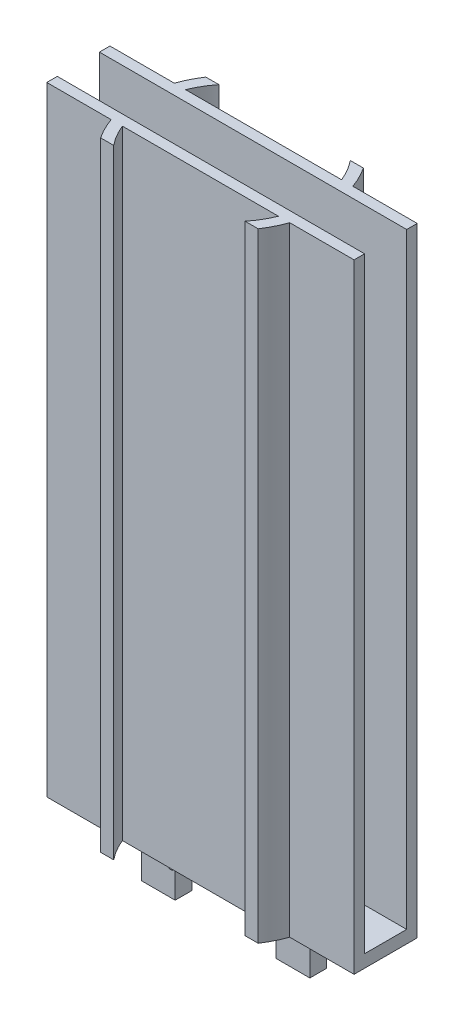
from build123d import *

# Parameters (mm, degrees)
BOSS_EXTRUDE1_DEPTH = 3
BOSS_EXTRUDE2_START = 144
BOSS_EXTRUDE2_DEPTH = 144
SKETCH2_W           = 8
SKETCH2_H           = 4
BOSS_EXTRUDE3_DEPTH = 12
SKETCH3_R           = 0.75
CUT_EXTRUDE1_DEPTH  = 163.14191315


with BuildPart() as part:
    # Sketch1 → Boss-Extrude1 (new body)
    with BuildSketch(Plane(origin=(0, 0, 0), x_dir=(1, 0, 0), z_dir=(0, 1, 0))):
        with BuildLine():
            Line((-17.959503782, 12.5), (-55.040496218, 12.5))
            ThreePointArc((-55.040496218, 12.5), (-53.758525494, 15.106596746), (-52.112494996, 17.5))
            Line((-52.112494996, 17.5), (-55.208286934, 17.5))
            ThreePointArc((-55.208286934, 17.5), (-56.616693275, 15.078127389), (-57.713203436, 12.5))
            Line((-57.713203436, 12.5), (-73, 12.5))
            Line((-73, 12.5), (-73, -2.5))
            Line((-73, -2.5), (-57.713203436, -2.5))
            ThreePointArc((-57.713203436, -2.5), (-56.616693275, -5.078127389), (-55.208286934, -7.5))
            Line((-55.208286934, -7.5), (-52.112494996, -7.5))
            ThreePointArc((-52.112494996, -7.5), (-53.758525494, -5.106596746), (-55.040496218, -2.5))
            Line((-55.040496218, -2.5), (-17.959503782, -2.5))
            ThreePointArc((-17.959503782, -2.5), (-19.241474506, -5.106596746), (-20.887505004, -7.5))
            Line((-20.887505004, -7.5), (-17.791713066, -7.5))
            ThreePointArc((-17.791713066, -7.5), (-16.383306725, -5.078127389), (-15.286796564, -2.5))
            Line((-15.286796564, -2.5), (0, -2.5))
            Line((0, -2.5), (0, 12.5))
            Line((0, 12.5), (-15.286796564, 12.5))
            ThreePointArc((-15.286796564, 12.5), (-16.383306725, 15.078127389), (-17.791713066, 17.5))
            Line((-17.791713066, 17.5), (-20.887505004, 17.5))
            ThreePointArc((-20.887505004, 17.5), (-19.241474506, 15.106596746), (-17.959503782, 12.5))
        make_face()
    extrude(amount=-BOSS_EXTRUDE1_DEPTH)

    # Sketch1_4 → Boss-Extrude2 (add)
    with BuildSketch(Plane(origin=(0, 0, 0), x_dir=(1, 0, 0), z_dir=(0, 1, 0)).offset(BOSS_EXTRUDE2_START)):
        with BuildLine():
            Line((0, 10), (0, 12.5))
            Line((0, 12.5), (-15.286796564, 12.5))
            ThreePointArc((-15.286796564, 12.5), (-16.383306725, 15.078127389), (-17.791713066, 17.5))
            Line((-17.791713066, 17.5), (-20.887505004, 17.5))
            ThreePointArc((-20.887505004, 17.5), (-19.241474506, 15.106596746), (-17.959503782, 12.5))
            Line((-17.959503782, 12.5), (-55.040496218, 12.5))
            ThreePointArc((-55.040496218, 12.5), (-53.758525494, 15.106596746), (-52.112494996, 17.5))
            Line((-52.112494996, 17.5), (-55.208286934, 17.5))
            ThreePointArc((-55.208286934, 17.5), (-56.616693275, 15.078127389), (-57.713203436, 12.5))
            Line((-57.713203436, 12.5), (-73, 12.5))
            Line((-73, 12.5), (-73, 10))
            Line((-73, 10), (0, 10))
        make_face()
        with BuildLine():
            Line((-73, 0), (-73, -2.5))
            Line((-73, -2.5), (-57.713203436, -2.5))
            ThreePointArc((-57.713203436, -2.5), (-56.616693275, -5.078127389), (-55.208286934, -7.5))
            Line((-55.208286934, -7.5), (-52.112494996, -7.5))
            ThreePointArc((-52.112494996, -7.5), (-53.758525494, -5.106596746), (-55.040496218, -2.5))
            Line((-55.040496218, -2.5), (-17.959503782, -2.5))
            ThreePointArc((-17.959503782, -2.5), (-19.241474506, -5.106596746), (-20.887505004, -7.5))
            Line((-20.887505004, -7.5), (-17.791713066, -7.5))
            ThreePointArc((-17.791713066, -7.5), (-16.383306725, -5.078127389), (-15.286796564, -2.5))
            Line((-15.286796564, -2.5), (0, -2.5))
            Line((0, -2.5), (0, 0))
            Line((0, 0), (-73, 0))
        make_face()
    extrude(amount=-BOSS_EXTRUDE2_DEPTH)

    # Sketch2 → Boss-Extrude3 (add)
    with BuildSketch(Plane.XZ.offset(3)):
        with Locations((-52.5, -5.5)):
            Rectangle(SKETCH2_W, SKETCH2_H)
        with Locations((-20.5, -5.5)):
            Rectangle(SKETCH2_W, SKETCH2_H)
    extrude(amount=BOSS_EXTRUDE3_DEPTH)

    # Sketch3 → Cut-Extrude1 (cut, through all)
    with BuildSketch(Plane(origin=(0, 0, -7.5), x_dir=(-1, 0, 0), z_dir=(0, 0, -1))):
        with Locations((23.5, -8.5)):
            Circle(SKETCH3_R)
        with Locations((49.5, -8.5)):
            Circle(SKETCH3_R)
    extrude(amount=-CUT_EXTRUDE1_DEPTH, mode=Mode.SUBTRACT)


solid = part.part
